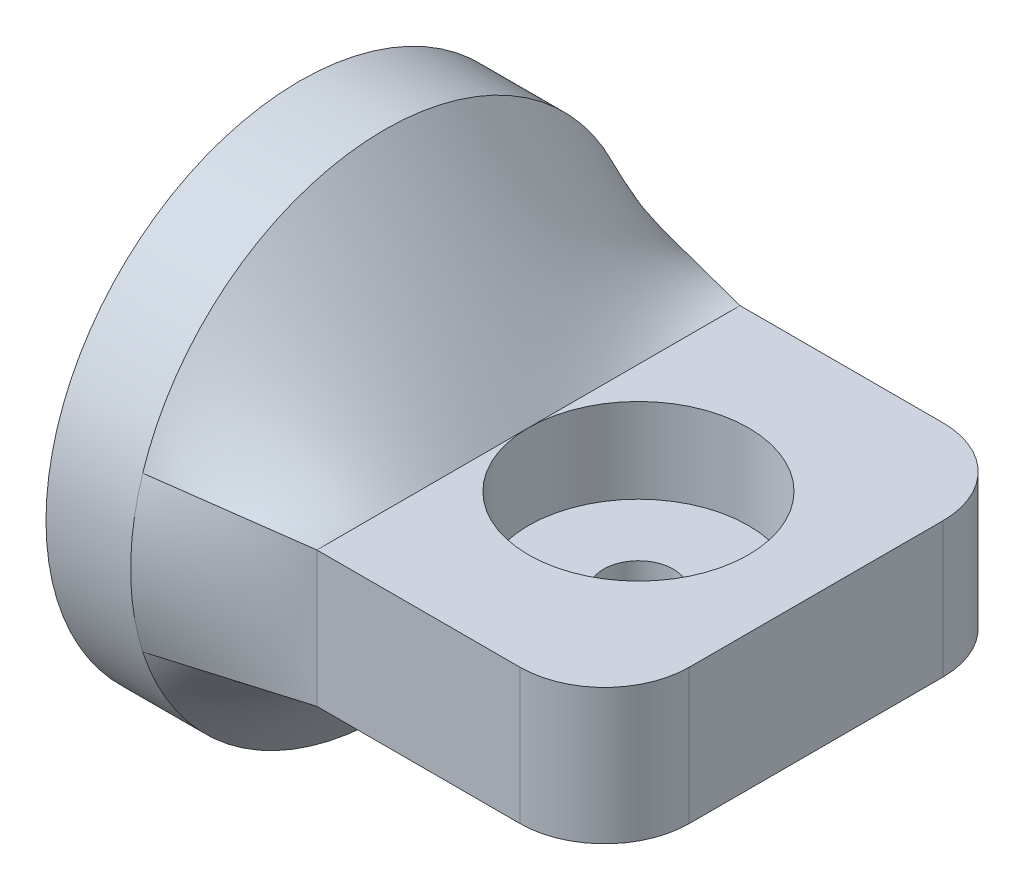
from build123d import *

# Parameters (mm, degrees)
SKETCH2_3_W             = 25
SKETCH2_3_H             = 8
BOSS_EXTRUDE1_DEPTH     = 17
FILLET2_R               = 5
CUT_EXTRUDE2_DEPTH      = 4
CUT_EXTRUDE2_DEPTH_BACK = 1
SKETCH3_R               = 6.5
SKETCH4_R               = 15
SKETCH4_R_2             = 6.5
BOSS_EXTRUDE2_DEPTH     = 5
SKETCH5_R               = 2.05
CUT_EXTRUDE3_DEPTH      = 3


with BuildPart() as part:
    # Sketch1 for Loft1 → Loft1 section 0
    with BuildSketch(Plane(origin=(0, 0, 0), x_dir=(0, 0, -1), z_dir=(1, 0, 0))):
        with BuildLine():
            # circular arc as an exact rational Bezier (weights 1, cos(half-angle), 1)
            Bezier((-14.286362208, -4.571635907), (0, -49.216517801), (14.286362208, -4.571635907), weights=[1, 0.304775727, 1])
            Bezier((14.286362208, -4.571635907), (15.749285698, 0), (14.286362208, 4.571635907), weights=[1, 0.952424147, 1])
            Bezier((14.286362208, 4.571635907), (0, 49.216517801), (-14.286362208, 4.571635907), weights=[1, 0.304775727, 1])
            Bezier((-14.286362208, 4.571635907), (-15.749285698, 0), (-14.286362208, -4.571635907), weights=[1, 0.952424147, 1])
        make_face()
    # Sketch2 → Loft1 section 1
    with BuildSketch(Plane(origin=(8.5, 0, 0), x_dir=(0, 0, -1), z_dir=(1, 0, 0))):
        with BuildLine():
            Line((-12.5, -4), (12.5, -4))
            Line((12.5, -4), (12.5, 4))
            Line((12.5, 4), (-12.5, 4))
            Line((-12.5, 4), (-12.5, -4))
        make_face()
    loft()

    # Sketch2_3 → Boss-Extrude1 (add)
    with BuildSketch(Plane(origin=(8.5, 0, 0), x_dir=(0, 0, -1), z_dir=(1, 0, 0))):
        Rectangle(SKETCH2_3_W, SKETCH2_3_H)
    extrude(amount=BOSS_EXTRUDE1_DEPTH)

    # Fillet2
    fillet2_edges = [part.edges().sort_by_distance(p)[0] for p in [
        (25.5, 0, 12.5),
        (25.5, 0, -12.5),
    ]]
    fillet(fillet2_edges, radius=FILLET2_R)

    # Sketch3 → Cut-Extrude2 (cut, two sides: drawn at the far end of the back side and taken through both)
    with BuildSketch(Plane(origin=(0, 0, 0), x_dir=(1, 0, 0), z_dir=(0, 1, 0)).offset(-CUT_EXTRUDE2_DEPTH_BACK)):
        with Locations((15, 0)):
            Circle(SKETCH3_R)
    extrude(amount=CUT_EXTRUDE2_DEPTH + CUT_EXTRUDE2_DEPTH_BACK, mode=Mode.SUBTRACT)

    # Sketch4 → Boss-Extrude2 (add)
    with BuildSketch(Plane.ZY):
        Circle(SKETCH4_R)
        Circle(SKETCH4_R_2, mode=Mode.SUBTRACT)
    extrude(amount=BOSS_EXTRUDE2_DEPTH)

    # Sketch5 → Cut-Extrude3 (cut)
    with BuildSketch(Plane(origin=(0, -1, 0), x_dir=(1, 0, 0), z_dir=(0, 1, 0))):
        with Locations((15, 0)):
            Circle(SKETCH5_R)
    extrude(amount=-CUT_EXTRUDE3_DEPTH, mode=Mode.SUBTRACT)


solid = part.part
